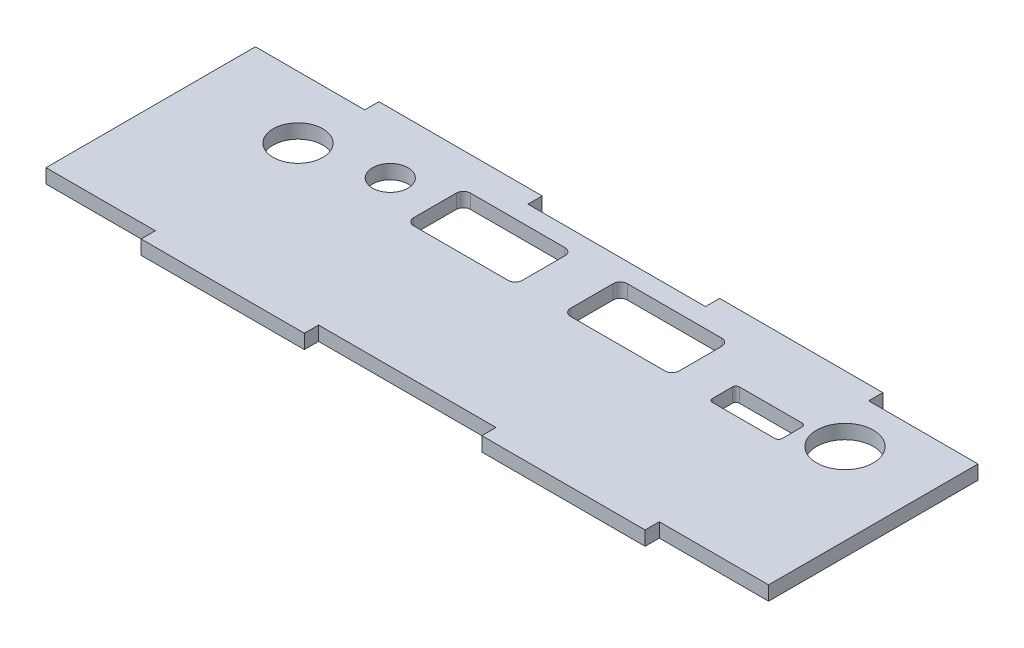
from build123d import *

# Parameters (mm, degrees)
SKETCH_1_W                     = 101.8
SKETCH_1_H                     = 29.5
EXTRUDE_1_DEPTH                = 2
SKETCH_2_W                     = 23
SKETCH_2_H                     = 2
EXTRUDE_2_DEPTH                = 2
SKETCH_3_R                     = 4
CUT_EXTRUDE_1_DEPTH            = 3
SKETCH_4_R                     = 3.5
CUT_EXTRUDE_2_DEPTH            = 3
SKETCH_5_R                     = 2.5
CUT_EXTRUDE_3_DEPTH            = 3
SKETCH_6_W                     = 15.3
SKETCH_6_H                     = 8
CUT_EXTRUDE_4_DEPTH            = 3
FILLET_1_R                     = 1
PATTERN_LINEAR_1_COUNT         = 2
PATTERN_LINEAR_1_PITCH         = 22.1
FILLET_1_OF_PATTERN_LINEAR_1_R = 1
SKETCH_7_W                     = 9.8
SKETCH_7_H                     = 3.8
CUT_EXTRUDE_5_DEPTH            = 3
FILLET_2_R                     = 0.5


with BuildPart() as part:
    # 草图1 → 凸台-拉伸1 (new body)
    with BuildSketch(Plane(origin=(0, 0, 0), x_dir=(1, 0, 0), z_dir=(0, 1, 0))):
        Rectangle(SKETCH_1_W, SKETCH_1_H)
    extrude(amount=EXTRUDE_1_DEPTH)

    # 草图2 → 凸台-拉伸2 (add)
    with BuildSketch(Plane(origin=(0, 2, 0), x_dir=(1, 0, 0), z_dir=(0, 1, 0))):
        with Locations((-24, 15.75)):
            Rectangle(SKETCH_2_W, SKETCH_2_H)
        with Locations((24, 15.75)):
            Rectangle(SKETCH_2_W, SKETCH_2_H)
        with Locations((24, -15.75)):
            Rectangle(SKETCH_2_W, SKETCH_2_H)
        with Locations((-24, -15.75)):
            Rectangle(SKETCH_2_W, SKETCH_2_H)
    extrude(amount=-EXTRUDE_2_DEPTH)

    # 草图3 → 切除-拉伸1 (cut, through all)
    with BuildSketch(Plane(origin=(0, 2, 0), x_dir=(1, 0, 0), z_dir=(0, 1, 0))):
        with Locations((39.4, 7.51)):
            Circle(SKETCH_3_R)
    extrude(amount=-CUT_EXTRUDE_1_DEPTH, mode=Mode.SUBTRACT)

    # 草图4 → 切除-拉伸2 (cut, through all)
    with BuildSketch(Plane(origin=(0, 2, 0), x_dir=(1, 0, 0), z_dir=(0, 1, 0))):
        with Locations((-36.15, 6)):
            Circle(SKETCH_4_R)
    extrude(amount=-CUT_EXTRUDE_2_DEPTH, mode=Mode.SUBTRACT)

    # 草图5 → 切除-拉伸3 (cut, through all)
    with BuildSketch(Plane(origin=(0, 2, 0), x_dir=(1, 0, 0), z_dir=(0, 1, 0))):
        with Locations((-25.4, 8.25)):
            Circle(SKETCH_5_R)
    extrude(amount=-CUT_EXTRUDE_3_DEPTH, mode=Mode.SUBTRACT)

    # 草图6 → 切除-拉伸4 (cut, through all)
    with BuildSketch(Plane(origin=(0, 2, 0), x_dir=(1, 0, 0), z_dir=(0, 1, 0))):
        with Locations((-11.25, 8.05)):
            Rectangle(SKETCH_6_W, SKETCH_6_H)
    cut_extrude_4 = extrude(amount=-CUT_EXTRUDE_4_DEPTH, mode=Mode.SUBTRACT)

    # 圆角1
    fillet_1_edges = [part.edges().sort_by_distance(p)[0] for p in [
        (-18.9, 1, -4.05),
        (-18.9, 1, -12.05),
        (-3.6, 1, -12.05),
        (-3.6, 1, -4.05),
    ]]
    fillet(fillet_1_edges, radius=FILLET_1_R)

    # 阵列(线性)1: 切除-拉伸4 ×2
    with Locations(*[(i * PATTERN_LINEAR_1_PITCH, 0, 0) for i in range(1, PATTERN_LINEAR_1_COUNT)]):
        add(cut_extrude_4, mode=Mode.SUBTRACT)

    # 圆角1 of 阵列(线性)1
    fillet_1_of_pattern_linear_1_edges = [part.edges().sort_by_distance(p)[0] for p in [
        (3.2, 1, -4.05),
        (3.2, 1, -12.05),
        (18.5, 1, -12.05),
        (18.5, 1, -4.05),
    ]]
    fillet(fillet_1_of_pattern_linear_1_edges, radius=FILLET_1_OF_PATTERN_LINEAR_1_R)

    # 草图7 → 切除-拉伸5 (cut, through all)
    with BuildSketch(Plane(origin=(0, 2, 0), x_dir=(1, 0, 0), z_dir=(0, 1, 0))):
        with Locations((29.1, 5.45)):
            Rectangle(SKETCH_7_W, SKETCH_7_H)
    extrude(amount=-CUT_EXTRUDE_5_DEPTH, mode=Mode.SUBTRACT)

    # 圆角2
    fillet_2_edges = [part.edges().sort_by_distance(p)[0] for p in [
        (24.2, 1, -3.55),
        (24.2, 1, -7.35),
        (34, 1, -7.35),
        (34, 1, -3.55),
    ]]
    fillet(fillet_2_edges, radius=FILLET_2_R)


solid = part.part
